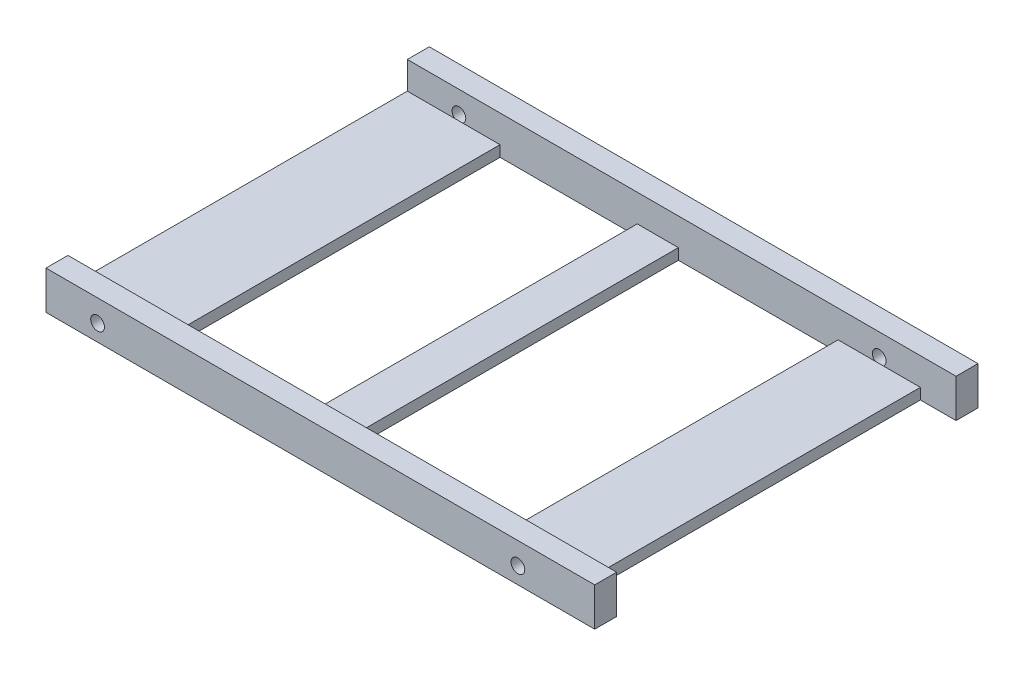
from build123d import *

# Parameters (mm, degrees)
SKETCH1_W           = 100
SKETCH1_H           = 69.85
BOSS_EXTRUDE1_DEPTH = 7
SKETCH2_R           = 1.25
CUT_EXTRUDE1_DEPTH  = 4
SKETCH3_W           = 25
SKETCH3_H           = 61.85
SKETCH3_W_2         = 29.1
SKETCH3_W_3         = 6.5
CUT_EXTRUDE2_DEPTH  = 8
SKETCH4_W           = 61.85
SKETCH4_H           = 5
CUT_EXTRUDE3_DEPTH  = 94.5


with BuildPart() as part:
    # Sketch1 → Boss-Extrude1 (new body)
    with BuildSketch(Plane(origin=(0, 0, 0), x_dir=(1, 0, 0), z_dir=(0, 1, 0))):
        with Locations((50, 34.925)):
            Rectangle(SKETCH1_W, SKETCH1_H)
    extrude(amount=BOSS_EXTRUDE1_DEPTH)

    # Sketch2 → Cut-Extrude1 (cut)
    with BuildSketch(Plane.XY):
        with Locations((86, 3)):
            Circle(SKETCH2_R)
        with Locations((9.4, 3)):
            Circle(SKETCH2_R)
    cut_extrude1 = extrude(amount=-CUT_EXTRUDE1_DEPTH, mode=Mode.SUBTRACT)

    # Sketch3 → Cut-Extrude2 (cut, through all)
    with BuildSketch(Plane(origin=(0, 7, 0), x_dir=(1, 0, 0), z_dir=(0, 1, 0))):
        with Locations((29.4, 34.925)):
            Rectangle(SKETCH3_W, SKETCH3_H)
        with Locations((63.95, 34.925)):
            Rectangle(SKETCH3_W_2, SKETCH3_H)
        with Locations((96.75, 34.925)):
            Rectangle(SKETCH3_W_3, SKETCH3_H)
    extrude(amount=-CUT_EXTRUDE2_DEPTH, mode=Mode.SUBTRACT)

    # Sketch4 → Cut-Extrude3 (cut, through all)
    with BuildSketch(Plane(origin=(93.5, 0, 0), x_dir=(0, 0, -1), z_dir=(1, 0, 0))):
        with Locations((34.925, 4.5)):
            Rectangle(SKETCH4_W, SKETCH4_H)
    extrude(amount=-CUT_EXTRUDE3_DEPTH, mode=Mode.SUBTRACT)

    # Mirror1: Cut-Extrude1 across plane
    add(cut_extrude1.mirror(Plane.XY.offset(-34.925)), mode=Mode.SUBTRACT)


solid = part.part
